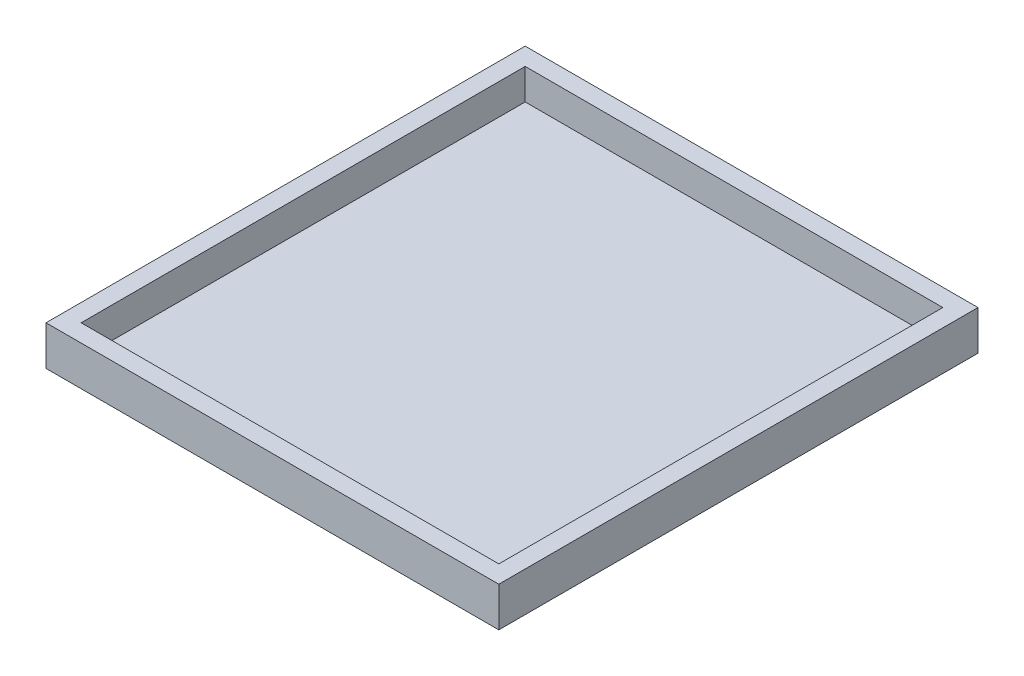
from build123d import *

# Parameters (mm, degrees)
SKETCH1_W           = 95
SKETCH1_H           = 101
BOSS_EXTRUDE1_DEPTH = 2
SKETCH2_W           = 103
SKETCH2_H           = 109
BOSS_EXTRUDE2_DEPTH = 7
CUT_EXTRUDE1_DEPTH  = 7
SKETCH4_W           = 103
SKETCH4_H           = 109
BOSS_EXTRUDE9_DEPTH = 2


with BuildPart() as part:
    # Sketch1 → Boss-Extrude1 (new body)
    with BuildSketch(Plane(origin=(0, 0, 0), x_dir=(1, 0, 0), z_dir=(0, 1, 0))):
        with Locations((0, -14.793667886)):
            Rectangle(SKETCH1_W, SKETCH1_H)
    extrude(amount=BOSS_EXTRUDE1_DEPTH)

    # Sketch2 → Boss-Extrude2 (add)
    with BuildSketch(Plane(origin=(0, 2, 0), x_dir=(1, 0, 0), z_dir=(0, 1, 0))):
        with Locations((0, -14.793667886)):
            Rectangle(SKETCH2_W, SKETCH2_H)
    extrude(amount=BOSS_EXTRUDE2_DEPTH)

    # Sketch3 → Cut-Extrude1 (cut)
    with BuildSketch(Plane(origin=(0, 9, 0), x_dir=(1, 0, 0), z_dir=(0, 1, 0))):
        Polygon((47.5, -65.060658177), (-47.5, 35.473322405), (-47.5, -65.293667886), (47.5, -65.293667886), align=None)
        Polygon((-47.5, 35.706332114), (-47.5, 35.473322405), (47.5, -65.060658177), (47.5, 35.706332114), align=None)
    extrude(amount=-CUT_EXTRUDE1_DEPTH, mode=Mode.SUBTRACT)

    # Sketch4 → Boss-Extrude9 (add, through all)
    with BuildSketch(Plane.XZ.offset(-2)):
        with Locations((0, 14.793667886)):
            Rectangle(SKETCH4_W, SKETCH4_H)
    extrude(amount=BOSS_EXTRUDE9_DEPTH)


solid = part.part
